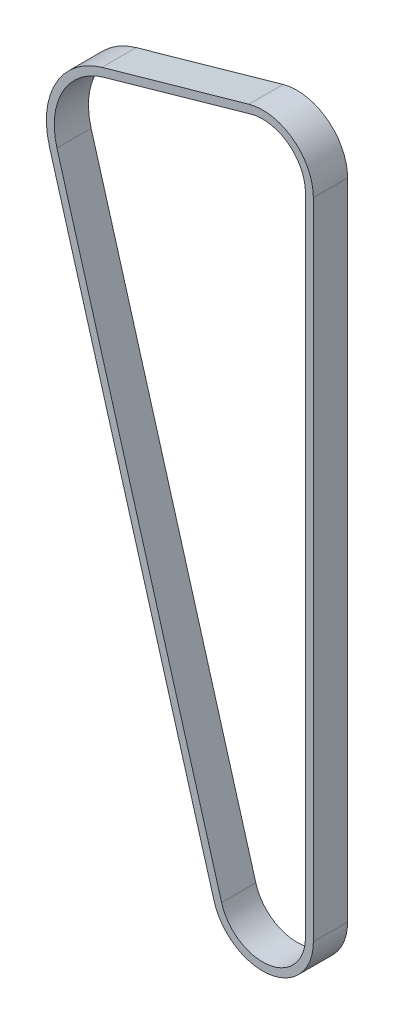
from build123d import *

# Parameters (mm, degrees)
EXTRUDE_THIN1_DEPTH = 6


with BuildPart() as part:
    # Sketch1 → Extrude-Thin1 (new body)
    with BuildSketch(Plane.XY):
        with BuildLine():
            Line((-13.659456823, 57.740319341), (12.1011413, 65.02640105))
            ThreePointArc((12.1011413, 65.02640105), (19.874859485, 63.563821837), (23.397935632, 56.481607012))
            Line((23.397935632, 56.481607012), (23.397935632, -56.481607012))
            ThreePointArc((23.397935632, -56.481607012), (15.760138751, -65.274293257), (5.985473603, -58.941585003))
            Line((5.985473603, -58.941585003), (-22.874280447, 41.15880473))
            ThreePointArc((-22.874280447, 41.15880473), (-21.7133002, 51.364842983), (-13.659456823, 57.740319341))
        make_face()
        with BuildLine():
            Line((-13.28387392, 56.41241216), (12.476724203, 63.698493868))
            ThreePointArc((12.476724203, 63.698493868), (19.042364562, 62.463207371), (22.017935632, 56.481607012))
            Line((22.017935632, 56.481607012), (22.017935632, -56.481607012))
            ThreePointArc((22.017935632, -56.481607012), (15.567093672, -63.907862287), (7.311464324, -58.559291126))
            Line((7.311464324, -58.559291126), (-21.548289726, 41.541098607))
            ThreePointArc((-21.548289726, 41.541098607), (-20.507051837, 50.694496143), (-13.28387392, 56.41241216))
        make_face(mode=Mode.SUBTRACT)
    extrude(amount=EXTRUDE_THIN1_DEPTH)


solid = part.part
